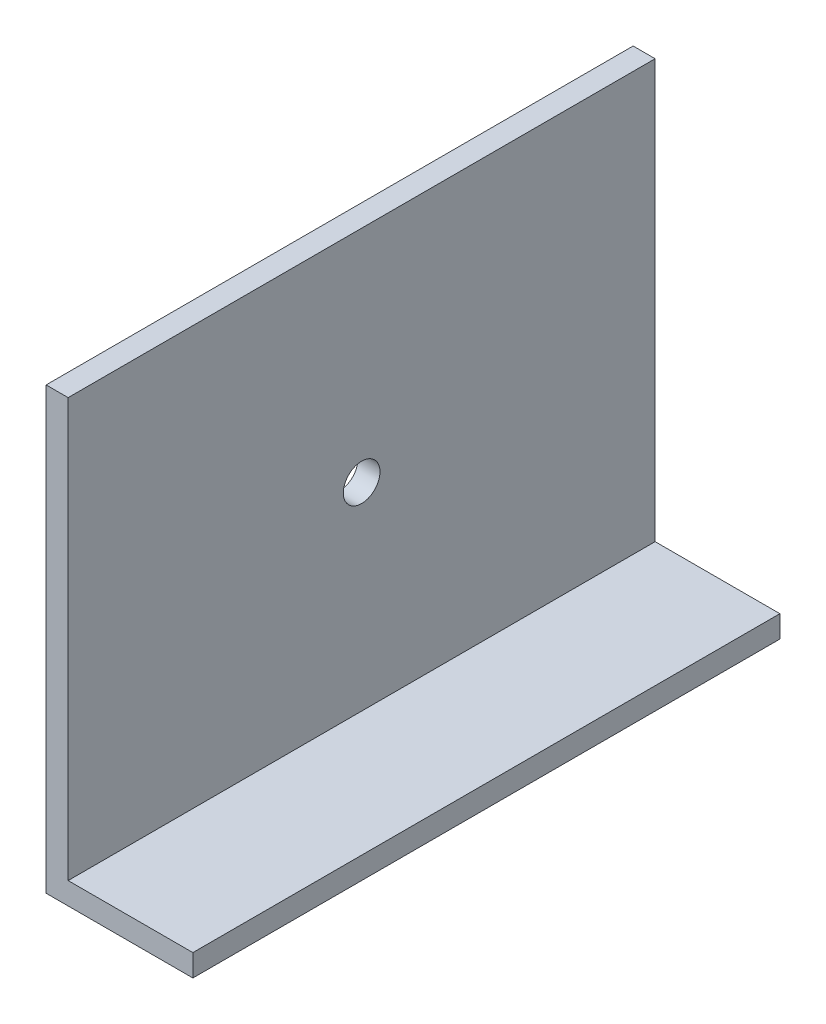
from build123d import *

# Parameters (mm, degrees)
BOSS_EXTRUDE1_DEPTH = 80
SKETCH2_R           = 2.5
CUT_EXTRUDE1_DEPTH  = 21


with BuildPart() as part:
    # Sketch1 → Boss-Extrude1 (new body)
    with BuildSketch(Plane.XY):
        Polygon((0, 0), (20, 0), (20, 3), (3, 3), (3, 60), (0, 60), align=None)
    extrude(amount=BOSS_EXTRUDE1_DEPTH)

    # Sketch2 → Cut-Extrude1 (cut, through all)
    with BuildSketch(Plane.ZY):
        with Locations((40, 30)):
            Circle(SKETCH2_R)
    extrude(amount=-CUT_EXTRUDE1_DEPTH, mode=Mode.SUBTRACT)


solid = part.part
